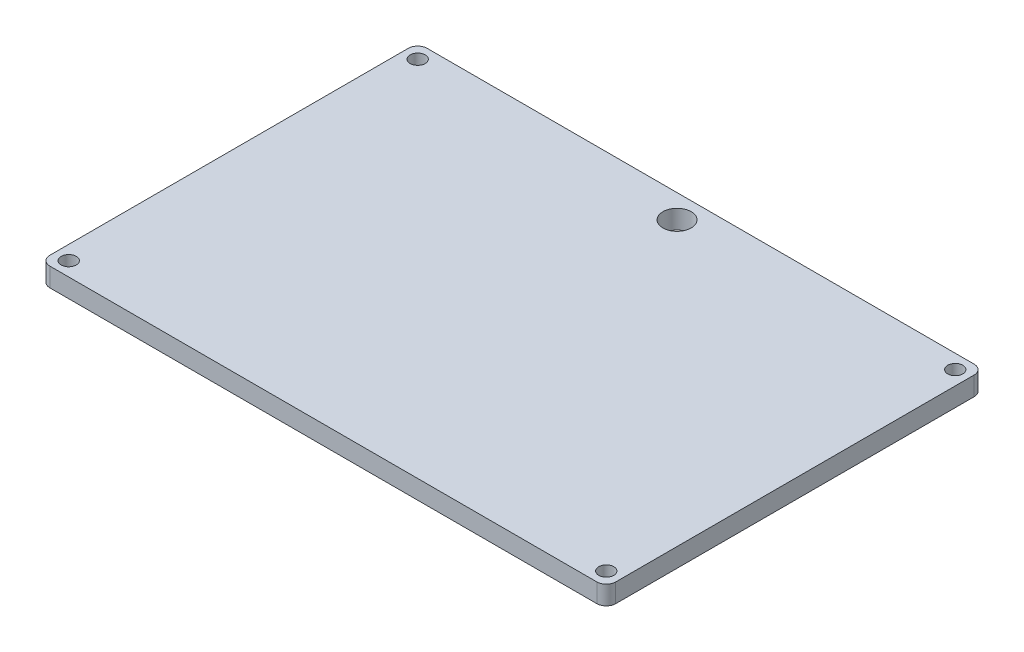
from build123d import *

# Parameters (mm, degrees)
SKETCH1_W           = 120
SKETCH1_H           = 80
SKETCH1_R           = 1.6
SKETCH1_R_2         = 3
BOSS_EXTRUDE1_DEPTH = 4
FILLET1_R           = 2
FILLET2_R           = 2
FILLET3_R           = 2
FILLET4_R           = 2


with BuildPart() as part:
    # Sketch1 → Boss-Extrude1 (new body)
    with BuildSketch(Plane(origin=(0, 0, 0), x_dir=(1, 0, 0), z_dir=(0, 1, 0))):
        with Locations((60, 40)):
            Rectangle(SKETCH1_W, SKETCH1_H)
        with Locations((3, 77)):
            Circle(SKETCH1_R, mode=Mode.SUBTRACT)
        with Locations((3, 3)):
            Circle(SKETCH1_R, mode=Mode.SUBTRACT)
        with Locations((117, 77)):
            Circle(SKETCH1_R, mode=Mode.SUBTRACT)
        with Locations((117, 3)):
            Circle(SKETCH1_R, mode=Mode.SUBTRACT)
        with Locations((60, 75)):
            Circle(SKETCH1_R_2, mode=Mode.SUBTRACT)
    extrude(amount=BOSS_EXTRUDE1_DEPTH)

    # Fillet1
    fillet1_edges = [part.edges().sort_by_distance(p)[0] for p in [
        (0, 2, 0),
    ]]
    fillet(fillet1_edges, radius=FILLET1_R)

    # Fillet2
    fillet2_edges = [part.edges().sort_by_distance(p)[0] for p in [
        (120, 2, 0),
    ]]
    fillet(fillet2_edges, radius=FILLET2_R)

    # Fillet3
    fillet3_edges = [part.edges().sort_by_distance(p)[0] for p in [
        (120, 2, -80),
    ]]
    fillet(fillet3_edges, radius=FILLET3_R)

    # Fillet4
    fillet4_edges = [part.edges().sort_by_distance(p)[0] for p in [
        (0, 2, -80),
    ]]
    fillet(fillet4_edges, radius=FILLET4_R)


solid = part.part
